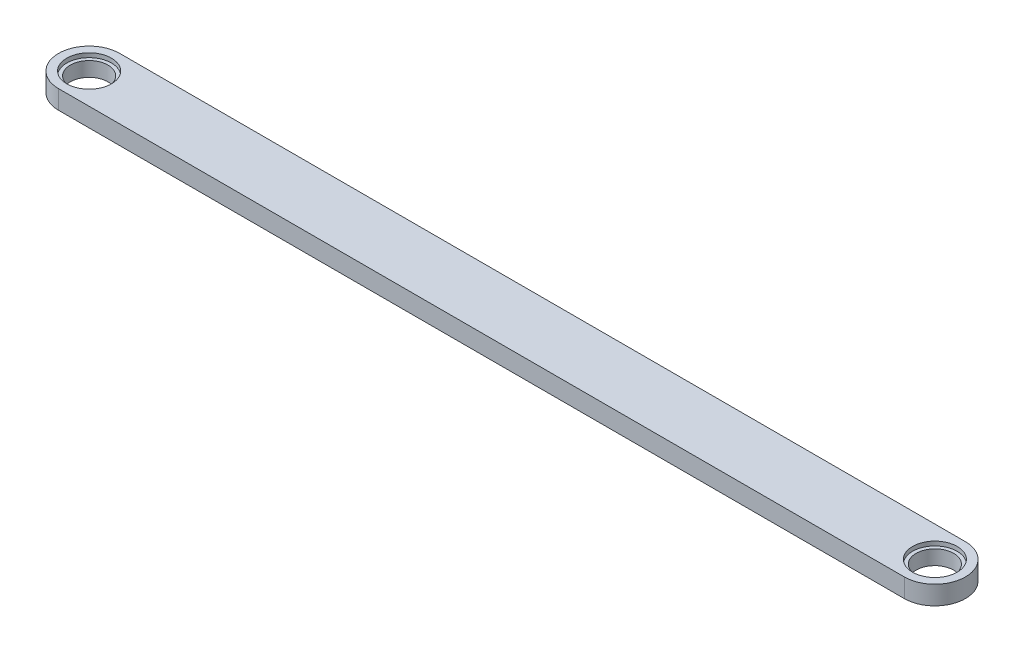
from build123d import *

# Parameters (mm, degrees)
EXTRUDE_1_DEPTH              = 4
HOLE_WIZARD_M5_1_D           = 8
HOLE_WIZARD_M5_1_CBORE_D     = 9.5
HOLE_WIZARD_M5_1_CBORE_DEPTH = 0.9


with BuildPart() as part:
    # 草图1 → 凸台-拉伸1 (new body)
    with BuildSketch(Plane(origin=(0, 0, 0), x_dir=(1, 0, 0), z_dir=(0, 1, 0))):
        with BuildLine():
            Line((0, 6.5), (180, 6.5))
            ThreePointArc((180, 6.5), (186.5, 0), (180, -6.5))
            Line((180, -6.5), (0, -6.5))
            ThreePointArc((0, -6.5), (-6.5, 0), (0, 6.5))
        make_face()
    extrude(amount=EXTRUDE_1_DEPTH)

    # M5 六角头螺栓的柱形沉头孔1 (through all)
    with Locations(Plane(origin=(0, 4, 0), x_dir=(1, 0, 0), z_dir=(0, 1, 0))):
        with Locations((180, 0), (0, 0)):
            CounterBoreHole(HOLE_WIZARD_M5_1_D / 2, HOLE_WIZARD_M5_1_CBORE_D / 2, HOLE_WIZARD_M5_1_CBORE_DEPTH)


solid = part.part
